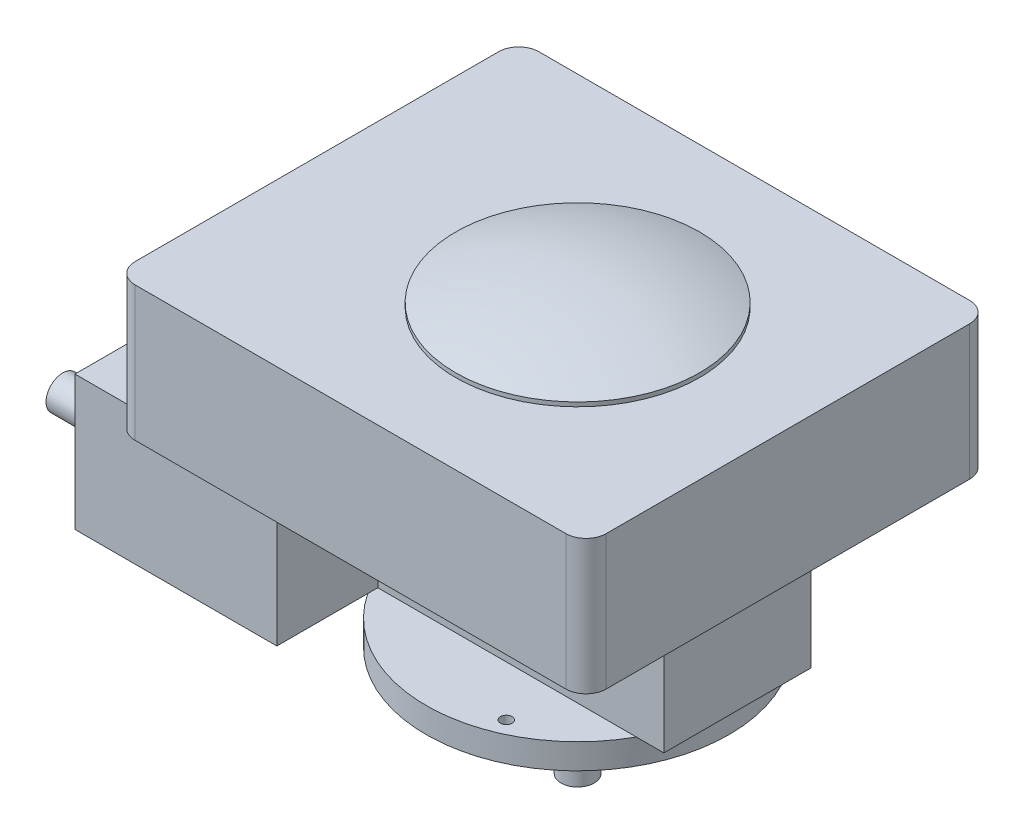
from build123d import *

# Parameters (mm, degrees)
SKETCH1_W           = 368.3
SKETCH1_H           = 111.125
BOSS_EXTRUDE1_DEPTH = 101.6
SKETCH2_R           = 114.3
BOSS_EXTRUDE2_DEPTH = 19.05
SKETCH3_R           = 87.63
BOSS_EXTRUDE3_DEPTH = 12.7
SKETCH4_R           = 12.5
BOSS_EXTRUDE4_DEPTH = 69.85
SKETCH5_W           = 355.6
SKETCH5_H           = 304.8
BOSS_EXTRUDE5_DEPTH = 101.6
SKETCH6_R           = 92.075
BOSS_EXTRUDE6_DEPTH = 3.175
DOME1_FACE_RADIUS   = 92.075
DOME1_HEIGHT        = 17.78
FILLET1_R           = 15.24
SKETCH7_W           = 152.4
SKETCH7_H           = 101.6
BOSS_EXTRUDE7_DEPTH = 76.2
SKETCH8_R           = 12.660326574
SKETCH8_R_2         = 10.120326574
EXTRUDE_THIN1_DEPTH = 25.4
CUT_EXTRUDE1_REACH  = 245.205
SKETCH9_R           = 4.365625


with BuildPart() as part:
    # Sketch1 → Boss-Extrude1 (new body)
    with BuildSketch(Plane(origin=(0, 0, 0), x_dir=(1, 0, 0), z_dir=(0, 1, 0))):
        with Locations((-63.5, 0)):
            Rectangle(SKETCH1_W, SKETCH1_H)
    extrude(amount=BOSS_EXTRUDE1_DEPTH)

    # Sketch2 → Boss-Extrude2 (add)
    with BuildSketch(Plane.XZ):
        with Locations(Location((0, 0, 0), (0, 0, 29.085295061))):  # turned: the seam where the file's is
            Circle(SKETCH2_R)
    extrude(amount=BOSS_EXTRUDE2_DEPTH)

    # Sketch3 → Boss-Extrude3 (add)
    with BuildSketch(Plane.XZ.offset(19.05)):
        with Locations(Location((0, 0, 0), (0, 0, 270))):  # turned: the seam where the file's is
            Circle(SKETCH3_R)
    extrude(amount=BOSS_EXTRUDE3_DEPTH)

    # Sketch4 → Boss-Extrude4 (add)
    with BuildSketch(Plane.XZ.offset(31.75)):
        with Locations(Location((0, 0, 0), (0, 0, 270))):  # turned: the seam where the file's is
            Circle(SKETCH4_R)
    extrude(amount=BOSS_EXTRUDE4_DEPTH)

    # Sketch5 → Boss-Extrude5 (add)
    with BuildSketch(Plane(origin=(0, 101.6, 0), x_dir=(1, 0, 0), z_dir=(0, 1, 0))):
        with Locations((-19.05, 0)):
            Rectangle(SKETCH5_W, SKETCH5_H)
    extrude(amount=BOSS_EXTRUDE5_DEPTH)

    # Sketch6 → Boss-Extrude6 (add)
    with BuildSketch(Plane(origin=(0, 203.2, 0), x_dir=(1, 0, 0), z_dir=(0, 1, 0))):
        with Locations(Location((0, 0, 0), (0, 0, 90))):  # turned: the seam where the file's is
            Circle(SKETCH6_R)
    extrude(amount=BOSS_EXTRUDE6_DEPTH)

    # Dome1: a dome of height H over a round flat face of radius A is a cap of a sphere of radius (A * A + H * H) / (2 * H)
    dome1_r = (DOME1_FACE_RADIUS * DOME1_FACE_RADIUS + DOME1_HEIGHT * DOME1_HEIGHT) / (2 * DOME1_HEIGHT)
    dome1_base = Plane((0, 206.375, 0), z_dir=(0, 1, 0))
    with Locations(dome1_base.offset(DOME1_HEIGHT - dome1_r)):
        dome1_ball = Sphere(dome1_r, mode=Mode.PRIVATE)
    add(split(dome1_ball, bisect_by=dome1_base, keep=Keep.TOP, mode=Mode.PRIVATE))

    # Fillet1
    fillet1_edges = [part.edges().sort_by_distance(p)[0] for p in [
        (158.75, 152.4, 152.4),
        (158.75, 152.4, -152.4),
        (-196.85, 152.4, -152.4),
        (-196.85, 152.4, 152.4),
    ]]
    fillet(fillet1_edges, radius=FILLET1_R)

    # Sketch7 → Boss-Extrude7 (add)
    with BuildSketch(Plane.XY.offset(55.5625)):
        with Locations((-171.45, 50.8)):
            Rectangle(SKETCH7_W, SKETCH7_H)
    extrude(amount=BOSS_EXTRUDE7_DEPTH)

    # Sketch8 → Extrude-Thin1 (add)
    with BuildSketch(Plane.ZY.offset(247.65)):
        with Locations((115.540395057, 68.867744931)):
            Circle(SKETCH8_R)
        with Locations((115.540395057, 68.867744931)):
            Circle(SKETCH8_R_2, mode=Mode.SUBTRACT)
    extrude(amount=EXTRUDE_THIN1_DEPTH)

    # Sketch9 → Cut-Extrude1 (cut, up to next)
    with BuildSketch(Plane.XZ.offset(19.05), mode=Mode.PRIVATE) as cut_extrude1_sk1:
        with Locations(Location((39.624, 93.472, 0), (0, 0, 270))):  # turned: the seam where the file's is
            Circle(SKETCH9_R)
    cut_extrude1_tool1 = extrude(cut_extrude1_sk1.sketch, amount=-CUT_EXTRUDE1_REACH, mode=Mode.PRIVATE) & part.part
    add(cut_extrude1_tool1.solids().sort_by_distance((39.624, -19.05, 93.472))[0], mode=Mode.SUBTRACT)
    # Sketch9 → Cut-Extrude1 (cut, up to next)
    with BuildSketch(Plane.XZ.offset(19.05), mode=Mode.PRIVATE) as cut_extrude1_sk2:
        with Locations(Location((76.708, -66.548, 0), (0, 0, 270))):  # turned: the seam where the file's is
            Circle(SKETCH9_R)
    cut_extrude1_tool2 = extrude(cut_extrude1_sk2.sketch, amount=-CUT_EXTRUDE1_REACH, mode=Mode.PRIVATE) & part.part
    add(cut_extrude1_tool2.solids().sort_by_distance((76.708, -19.05, -66.548))[0], mode=Mode.SUBTRACT)
    # Sketch9 → Cut-Extrude1 (cut, up to next)
    with BuildSketch(Plane.XZ.offset(19.05), mode=Mode.PRIVATE) as cut_extrude1_sk3:
        with Locations(Location((-81.28, -61.214, 0), (0, 0, 270))):  # turned: the seam where the file's is
            Circle(SKETCH9_R)
    cut_extrude1_tool3 = extrude(cut_extrude1_sk3.sketch, amount=-CUT_EXTRUDE1_REACH, mode=Mode.PRIVATE) & part.part
    add(cut_extrude1_tool3.solids().sort_by_distance((-81.28, -19.05, -61.214))[0], mode=Mode.SUBTRACT)


solid = part.part
